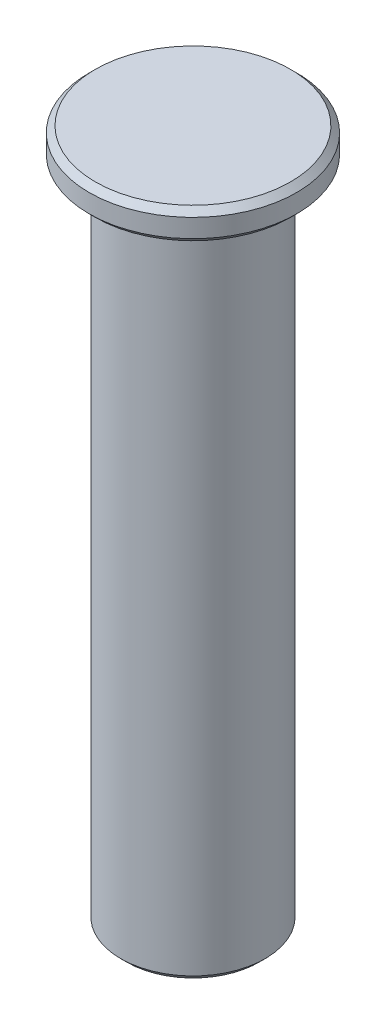
from build123d import *

# Parameters (mm, degrees)
SKETCH1_R           = 4.7
BOSS_EXTRUDE1_DEPTH = 45
SKETCH2_R           = 6.75
BOSS_EXTRUDE2_DEPTH = 2
CHAMFER2_SIZE       = 0.4
CHAMFER3_SIZE       = 0.4


with BuildPart() as part:
    # Sketch1 → Boss-Extrude1 (new body)
    with BuildSketch(Plane(origin=(0, 0, 0), x_dir=(1, 0, 0), z_dir=(0, 1, 0))):
        Circle(SKETCH1_R)
    extrude(amount=BOSS_EXTRUDE1_DEPTH)

    # Sketch2 → Boss-Extrude2 (add)
    with BuildSketch(Plane(origin=(0, 45, 0), x_dir=(1, 0, 0), z_dir=(0, 1, 0))):
        Circle(SKETCH2_R)
    extrude(amount=-BOSS_EXTRUDE2_DEPTH)

    # Chamfer2
    chamfer2_edges = [part.edges().sort_by_distance(p)[0] for p in [
        (-6.75, 43, 0),
        (-6.75, 45, 0),
    ]]
    chamfer(chamfer2_edges, length=CHAMFER2_SIZE)

    # Chamfer3
    chamfer3_edges = [part.edges().sort_by_distance(p)[0] for p in [
        (-4.7, 0, 0),
    ]]
    chamfer(chamfer3_edges, length=CHAMFER3_SIZE)


solid = part.part
